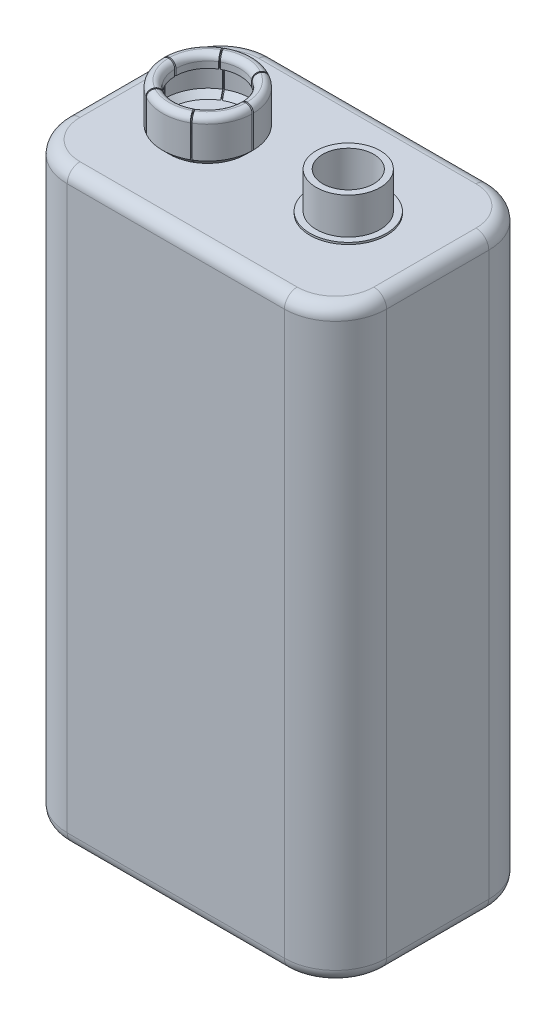
from build123d import *

# Parameters (mm, degrees)
SKETCH2_W           = 25
SKETCH2_H           = 16
BOSS_EXTRUDE1_DEPTH = 46
FILLET1_R           = 4
FILLET2_R           = 1
SKETCH3_R           = 2.5
SKETCH3_R_2         = 2
EXTRUDE_THIN1_DEPTH = 3
SKETCH6_R           = 1
BOSS_EXTRUDE2_DEPTH = 0.75
SKETCH10_W          = 1.5
SKETCH10_H          = 0.1
CUT_EXTRUDE1_DEPTH  = 4.375498081
CIRPATTERN1_COUNT   = 6
SKETCH11_R          = 3
BOSS_EXTRUDE3_DEPTH = 0.15


with BuildPart() as part:
    # Sketch2 → Boss-Extrude1 (new body)
    with BuildSketch(Plane(origin=(0, 0, 0), x_dir=(1, 0, 0), z_dir=(0, 1, 0))):
        Rectangle(SKETCH2_W, SKETCH2_H)
    extrude(amount=BOSS_EXTRUDE1_DEPTH)

    # Fillet1
    fillet1_edges = [part.edges().sort_by_distance(p)[0] for p in [
        (12.5, 23, 8),
        (-12.5, 23, 8),
        (-12.5, 23, -8),
        (12.5, 23, -8),
    ]]
    fillet(fillet1_edges, radius=FILLET1_R)

    # Fillet2
    fillet2_edges = [part.edges().sort_by_distance(p)[0] for p in [
        (-12.5, 0, 0),
        (-12.5, 46, 0),
        (12.5, 0, 0),
        (0, 0, 8),
        (0, 0, -8),
        (11.328427125, 0, 6.828427125),
        (11.328427125, 0, -6.828427125),
        (-11.328427125, 0, 6.828427125),
        (-11.328427125, 0, -6.828427125),
        (0, 46, -8),
        (12.5, 46, 0),
        (0, 46, 8),
        (11.328427125, 46, 6.828427125),
        (11.328427125, 46, -6.828427125),
        (-11.328427125, 46, 6.828427125),
        (-11.328427125, 46, -6.828427125),
    ]]
    fillet(fillet2_edges, radius=FILLET2_R)

    # Sketch3 → Extrude-Thin1 (add)
    with BuildSketch(Plane(origin=(0, 46, 0), x_dir=(1, 0, 0), z_dir=(0, 1, 0))):
        with Locations((5.5, 0)):
            Circle(SKETCH3_R)
        with Locations((5.5, 0)):
            Circle(SKETCH3_R_2, mode=Mode.SUBTRACT)
    extrude(amount=EXTRUDE_THIN1_DEPTH)

    # Sketch6 → Boss-Extrude2 (add)
    with BuildSketch(Plane(origin=(0, 46, 0), x_dir=(1, 0, 0), z_dir=(0, 1, 0))):
        with Locations((-5.5, 0)):
            Circle(SKETCH6_R)
        with Locations((5.5, 0)):
            Circle(SKETCH6_R)
    extrude(amount=BOSS_EXTRUDE2_DEPTH)

    # Sketch9 → Revolve-Thin1 (revolve)
    with BuildSketch(Plane.XY):
        with BuildLine():
            Line((-4.5, 46), (-2.5, 46))
            Line((-2.5, 46), (-1.969669914, 46.530330086))
            Line((-1.969669914, 46.530330086), (-1.969669914, 49.030330086))
            ThreePointArc((-1.969669914, 49.030330086), (-2.116202444, 49.381961465), (-2.469074773, 49.525479854))
            ThreePointArc((-2.469074773, 49.525479854), (-2.819198532, 49.380453844), (-2.964224541, 49.030330086))
            Line((-2.964224541, 49.030330086), (-2.964224541, 48.535180318))
            Line((-2.964224541, 48.535180318), (-2.814224541, 48.535180318))
            Line((-2.814224541, 48.535180318), (-2.814224541, 49.030330086))
            ThreePointArc((-2.814224541, 49.030330086), (-2.712905513, 49.274614618), (-2.468433015, 49.375479257))
            ThreePointArc((-2.468433015, 49.375479257), (-2.222041674, 49.27566845), (-2.119669914, 49.030330086))
            Line((-2.119669914, 49.030330086), (-2.119669914, 46.59246212))
            Line((-2.119669914, 46.59246212), (-2.562132034, 46.15))
            Line((-2.562132034, 46.15), (-4.5, 46.15))
            Line((-4.5, 46.15), (-4.5, 46))
        make_face()
    revolve(axis=Axis((-5.5, 46.75, 0), (0, -1, 0)))

    # Sketch10 → Cut-Extrude1 (cut, through all)
    with BuildSketch(Plane(origin=(0, 46.15, 0), x_dir=(1, 0, 0), z_dir=(0, 1, 0))):
        with Locations((-2.469074773, 0)):
            Rectangle(SKETCH10_W, SKETCH10_H)
    cut_extrude1 = extrude(amount=CUT_EXTRUDE1_DEPTH, mode=Mode.SUBTRACT)

    # CirPattern1: Cut-Extrude1 ×6 about axis
    cirpattern1_axis = Axis((-5.5, 0, 0), (0, 1, 0))
    for i in range(1, CIRPATTERN1_COUNT):
        add(cut_extrude1.rotate(cirpattern1_axis, i * 360 / CIRPATTERN1_COUNT), mode=Mode.SUBTRACT)

    # Sketch11 → Boss-Extrude3 (add)
    with BuildSketch(Plane(origin=(0, 46, 0), x_dir=(1, 0, 0), z_dir=(0, 1, 0))):
        with Locations((5.5, 0)):
            Circle(SKETCH11_R)
    extrude(amount=BOSS_EXTRUDE3_DEPTH)


solid = part.part
